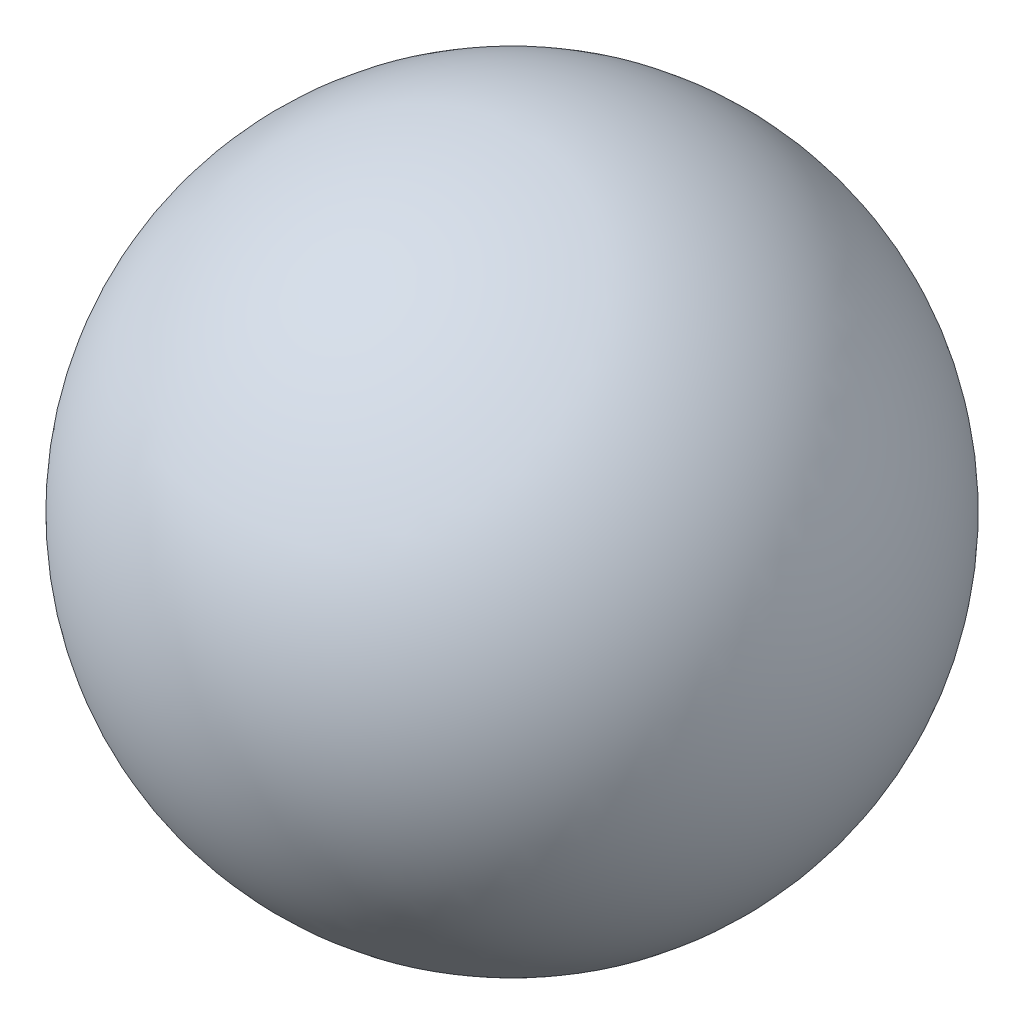
from build123d import *


with BuildPart() as part:
    # Sketch1 → Revolve3 (revolve)
    with BuildSketch(Plane.XY):
        with BuildLine():
            Line((0, 7.5), (0, -7.5))
            ThreePointArc((0, -7.5), (7.5, 0), (0, 7.5))
        make_face()
    revolve(axis=Axis((0, 7.5, 0), (0, -1, 0)))


solid = part.part
